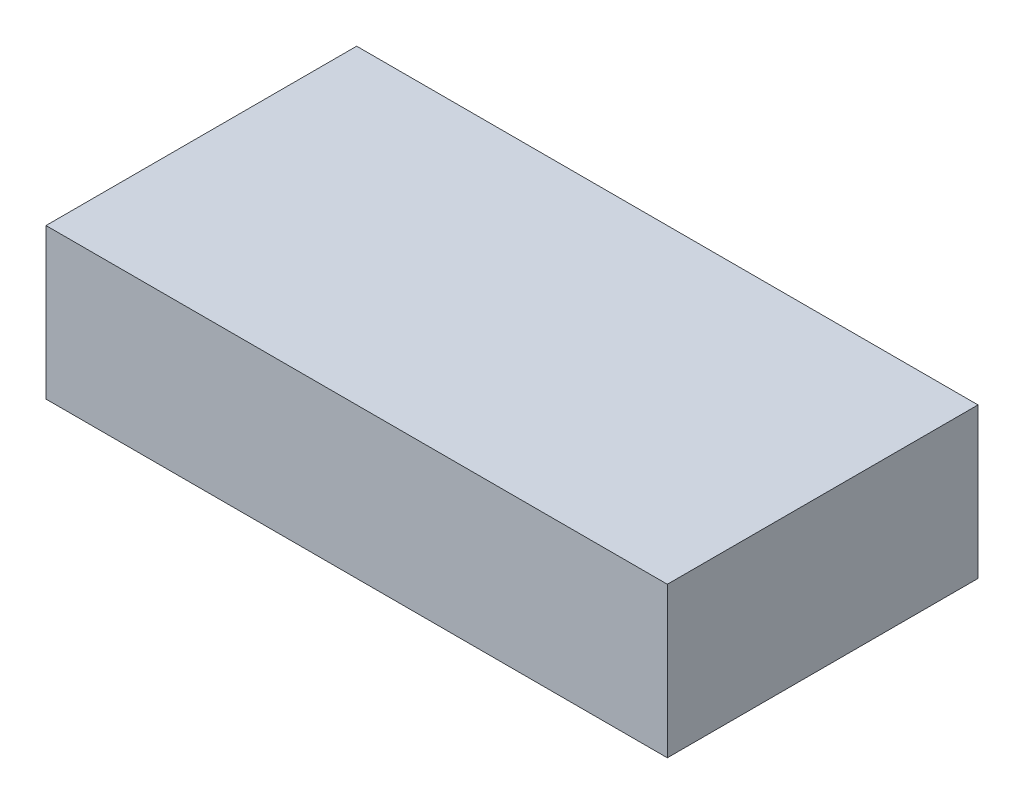
from build123d import *

# Parameters (mm, degrees)
SKETCH1_W           = 62
SKETCH1_H           = 31
BOSS_EXTRUDE1_DEPTH = 15


with BuildPart() as part:
    # Sketch1 → Boss-Extrude1 (new body)
    with BuildSketch(Plane(origin=(0, 0, 0), x_dir=(1, 0, 0), z_dir=(0, 1, 0))):
        Rectangle(SKETCH1_W, SKETCH1_H)
    extrude(amount=BOSS_EXTRUDE1_DEPTH)


solid = part.part
